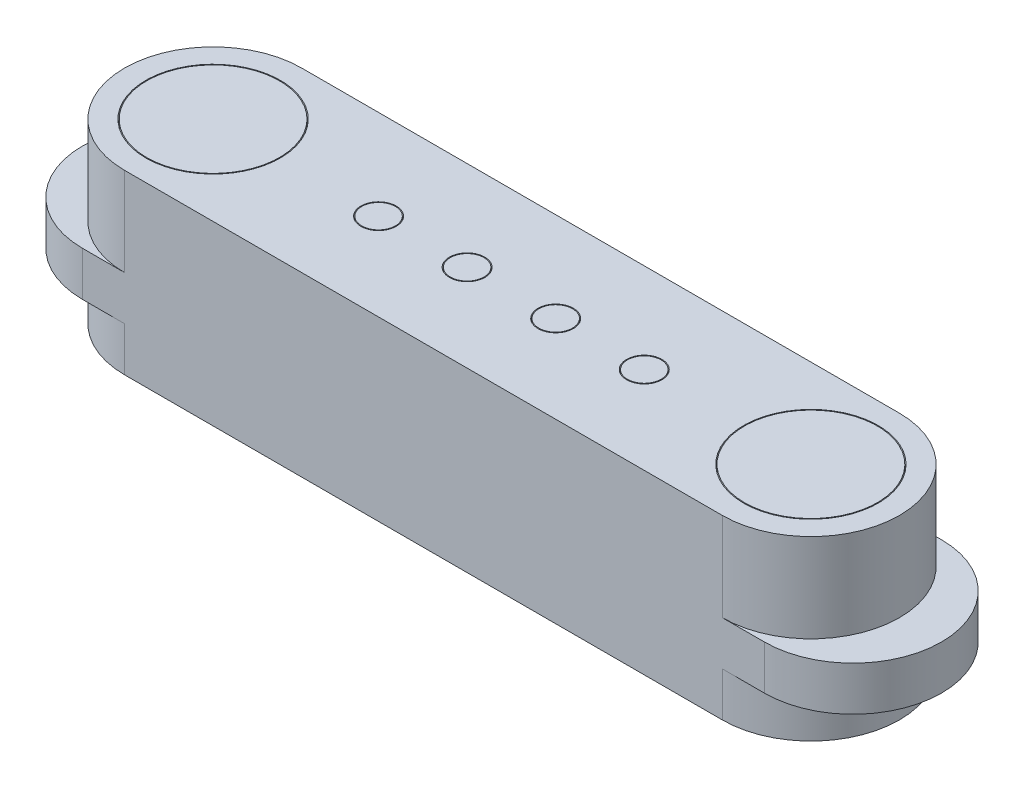
from build123d import *

# Parameters (mm, degrees)
BOSS_EXTRUDE1_DEPTH = 2
BOSS_EXTRUDE2_START = -1
BOSS_EXTRUDE2_DEPTH = 0.5
SKETCH3_R           = 0.76
SKETCH3_R_2         = 0.75
SKETCH3_R_3         = 0.199685651
SKETCH3_R_4         = 0.189685651
CUT_EXTRUDE1_DEPTH  = 0.1
SCALE1_SCALE        = 2


with BuildPart() as part:
    # Sketch1 → Boss-Extrude1 (new body)
    with BuildSketch(Plane(origin=(0, 0, 0), x_dir=(1, 0, 0), z_dir=(0, 1, 0))):
        with BuildLine():
            Line((-3.375, 1), (3.375, 1))
            ThreePointArc((3.375, 1), (4.375, 0), (3.375, -1))
            Line((3.375, -1), (-3.375, -1))
            ThreePointArc((-3.375, -1), (-4.375, 0), (-3.375, 1))
        make_face()
    extrude(amount=BOSS_EXTRUDE1_DEPTH)

    # Sketch2 → Boss-Extrude2 (add)
    with BuildSketch(Plane(origin=(0, 2, 0), x_dir=(1, 0, 0), z_dir=(0, 1, 0)).offset(BOSS_EXTRUDE2_START)):
        with BuildLine():
            Line((-3.85, 1), (3.85, 1))
            ThreePointArc((3.85, 1), (4.85, 0), (3.85, -1))
            Line((3.85, -1), (-3.85, -1))
            ThreePointArc((-3.85, -1), (-4.85, 0), (-3.85, 1))
        make_face()
    extrude(amount=-BOSS_EXTRUDE2_DEPTH)

    # Sketch3 → Cut-Extrude1 (cut)
    with BuildSketch(Plane(origin=(0, 2, 0), x_dir=(1, 0, 0), z_dir=(0, 1, 0))):
        with Locations((-3.375, 0)):
            Circle(SKETCH3_R)
        with Locations((-3.375, 0)):
            Circle(SKETCH3_R_2, mode=Mode.SUBTRACT)
        with Locations((-1.492185541, -0.014395915)):
            Circle(SKETCH3_R_3)
        with Locations((-1.492185541, -0.014395915)):
            Circle(SKETCH3_R_4, mode=Mode.SUBTRACT)
        with Locations((-0.492185541, -0.014395915)):
            Circle(SKETCH3_R_3)
        with Locations((-0.492185541, -0.014395915)):
            Circle(SKETCH3_R_4, mode=Mode.SUBTRACT)
        with Locations((0.507814459, -0.014395915)):
            Circle(SKETCH3_R_3)
        with Locations((0.507814459, -0.014395915)):
            Circle(SKETCH3_R_4, mode=Mode.SUBTRACT)
        with Locations((1.507814459, -0.014395915)):
            Circle(SKETCH3_R_3)
        with Locations((1.507814459, -0.014395915)):
            Circle(SKETCH3_R_4, mode=Mode.SUBTRACT)
        with Locations((3.375, 0)):
            Circle(SKETCH3_R)
        with Locations((3.375, 0)):
            Circle(SKETCH3_R_2, mode=Mode.SUBTRACT)
    extrude(amount=-CUT_EXTRUDE1_DEPTH, mode=Mode.SUBTRACT)


with BuildPart() as part_1:
    # Scale1: scaled about (-1.117e-06, 0.99266013, -2.058e-06)
    add(part.part.scale(SCALE1_SCALE).moved(Location((1.117e-06, -0.99266013, 2.058e-06))))


solid = part_1.part
